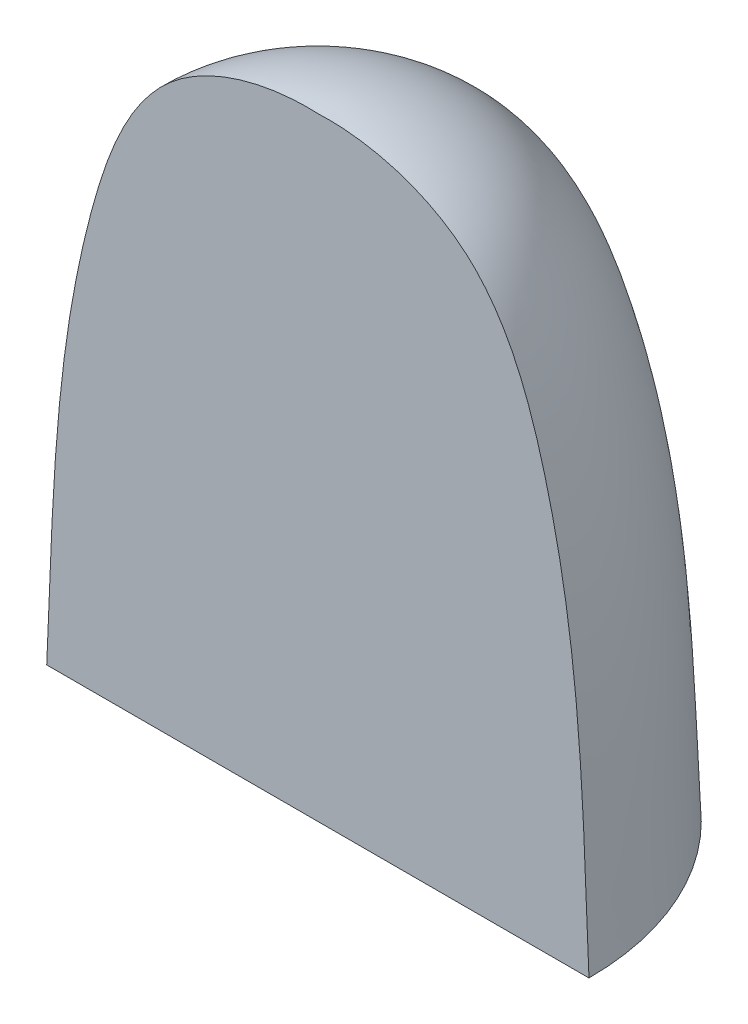
from build123d import *

# Parameters (mm, degrees)
SKETCH2_W           = 22.16775651
SKETCH2_H           = 25.111868119
CUT_EXTRUDE1_DEPTH  = 9
BOSS_EXTRUDE1_DEPTH = 1


with BuildPart() as part:
    # Sketch1 → Revolve1 (revolve)
    with BuildSketch(Plane.XY):
        with BuildLine():
            Line((6.5, 0), (9, 0))
            add(Edge.make_bspline(
                [(0, 20.35), (1.675966842, 20.428176516), (5.66035993, 19.372470149), (8.740520085, 10.941984052), (8.794057121, 4.785623995), (9, 0)],
                knots=[0, 0, 0, 0, 0.209086974, 0.440428739, 1, 1, 1, 1], degree=3))
            Line((0, 20.35), (0, 17.85))
            add(Edge.make_bspline(
                [(0, 17.85), (1.248468613, 18.003104069), (3.434295374, 16.83334968), (6.617297319, 10.514055415), (6.220398856, 4.532307189), (6.5, 0)],
                knots=[0, 0, 0, 0, 0.174730572, 0.328981961, 1, 1, 1, 1], degree=3))
        make_face()
    revolve(axis=Axis((0, 24.080193906, 0), (0, -1, 0)))

    # Sketch2 → Cut-Extrude1 (cut)
    with BuildSketch(Plane.XY.offset(9)):
        with Locations((0.864101602, 11.007607196)):
            Rectangle(SKETCH2_W, SKETCH2_H)
    extrude(amount=-CUT_EXTRUDE1_DEPTH, mode=Mode.SUBTRACT)

    # Sketch3 → Boss-Extrude1 (add)
    with BuildSketch(Plane.XY):
        with BuildLine():
            Line((-7.75, 0), (7.75, 0))
            add(Edge.make_bspline(
                [(-7.75, 0), (-8.003711251, 4.491264664), (-7.661665361, 10.48327828), (-4.662420922, 18.274599737), (0.148702201, 19.617208041), (4.677365419, 17.883192424), (7.773890001, 10.39627401), (7.411285563, 4.341150012), (7.75, 0)],
                knots=[0, 0, 0, 0, 0.289463592, 0.419223785, 0.501869976, 0.592483788, 0.714941347, 1, 1, 1, 1], degree=3))
        make_face()
    extrude(amount=-BOSS_EXTRUDE1_DEPTH)


solid = part.part
